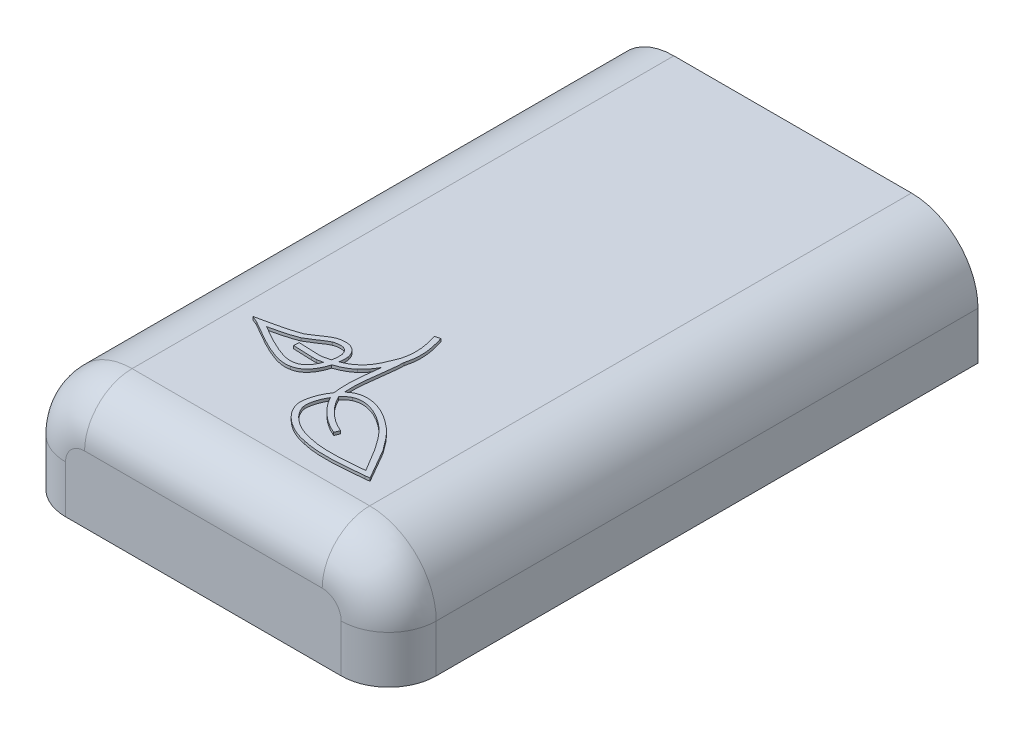
from build123d import *

# Parameters (mm, degrees)
BOSS_EXTRUDE1_DEPTH = 60
BOSS_EXTRUDE2_DEPTH = 2
BOSS_EXTRUDE3_START = 60
BOSS_EXTRUDE3_DEPTH = 2
FILLET1_R           = 5
BOSS_EXTRUDE4_DEPTH = 0.3


with BuildPart() as part:
    # Sketch1 → Boss-Extrude1 (new body)
    with BuildSketch(Plane.XY):
        with BuildLine():
            Line((-12.5, 0), (12.5, 0))
            ThreePointArc((12.5, 0), (16.035533906, -1.464466094), (17.5, -5))
            Line((17.5, -5), (17.5, -10))
            Line((17.5, -10), (19.5, -10))
            Line((19.5, -10), (19.5, -5))
            ThreePointArc((19.5, -5), (17.449747468, -0.050252532), (12.5, 2))
            Line((12.5, 2), (-12.5, 2))
            ThreePointArc((-12.5, 2), (-17.449747468, -0.050252532), (-19.5, -5))
            Line((-19.5, -5), (-19.5, -10))
            Line((-19.5, -10), (-17.5, -10))
            Line((-17.5, -10), (-17.5, -5))
            ThreePointArc((-17.5, -5), (-16.035533906, -1.464466094), (-12.5, 0))
        make_face()
    extrude(amount=BOSS_EXTRUDE1_DEPTH)

    # Sketch2 → Boss-Extrude2 (add)
    with BuildSketch(Plane.XY):
        with BuildLine():
            Line((19.5, -10), (19.5, -5))
            ThreePointArc((19.5, -5), (17.449747468, -0.050252532), (12.5, 2))
            Line((12.5, 2), (-12.5, 2))
            ThreePointArc((-12.5, 2), (-17.449747468, -0.050252532), (-19.5, -5))
            Line((-19.5, -5), (-19.5, -10))
            Line((-19.5, -10), (19.5, -10))
        make_face()
    extrude(amount=BOSS_EXTRUDE2_DEPTH)

    # Sketch2_2 → Boss-Extrude3 (add)
    with BuildSketch(Plane.XY.offset(BOSS_EXTRUDE3_START)):
        with BuildLine():
            Line((19.5, -10), (19.5, -5))
            ThreePointArc((19.5, -5), (17.449747468, -0.050252532), (12.5, 2))
            Line((12.5, 2), (-12.5, 2))
            ThreePointArc((-12.5, 2), (-17.449747468, -0.050252532), (-19.5, -5))
            Line((-19.5, -5), (-19.5, -10))
            Line((-19.5, -10), (19.5, -10))
        make_face()
    extrude(amount=BOSS_EXTRUDE3_DEPTH)

    # Fillet1
    fillet1_edges = [part.edges().sort_by_distance(p)[0] for p in [
        (-17.5, -7.5, 60),
        (-16.035533906, -1.464466094, 60),
        (0, 0, 60),
        (16.035533906, -1.464466094, 60),
        (-17.449747468, -0.050252532, 62),
        (17.449747468, -0.050252532, 62),
        (-19.5, -7.5, 62),
        (19.5, -7.5, 62),
        (0, 2, 62),
        (17.5, -7.5, 60),
    ]]
    fillet(fillet1_edges, radius=FILLET1_R)

    # Sketch4 → Boss-Extrude4 (add)
    with BuildSketch(Plane(origin=(0, 2, 0), x_dir=(1, 0, 0), z_dir=(0, 1, 0))):
        with BuildLine():
            Line((1.305736018, -38.316257091), (0.769961661, -38.466050797))
            add(Edge.make_bspline(
                [(0.967943194, -42.312720401), (1.020082146, -42.130005014), (1.110807126, -41.744125018), (1.200733766, -41.051660621), (1.183460904, -40.246056299), (1.017384191, -39.352294709), (0.852316866, -38.760614624), (0.769961661, -38.466050797)],
                knots=[0.002817102, 0.002817102, 0.002817102, 0.002817102, 0.125, 0.25, 0.5, 0.75, 1, 1, 1, 1], degree=3))
            add(Edge.make_bspline(
                [(-0.376582831, -44.774852536), (-0.226435782, -44.638475717), (0.02847593, -44.342224393), (0.377548216, -43.739641888), (0.680988093, -43.054163966), (0.873973024, -42.555843286), (0.967943194, -42.312720401)],
                knots=[0, 0, 0, 0, 0.251945629, 0.503891258, 0.755836887, 1.003516675, 1.003516675, 1.003516675, 1.003516675], degree=3))
            add(Edge.make_bspline(
                [(-1.932240131, -45.787781805), (-1.844054211, -45.755294083), (-1.496544164, -45.617487412), (-0.940875039, -45.321573069), (-0.548437196, -44.972120594), (-0.376582831, -44.774852536)],
                knots=[0.410600718, 0.410600718, 0.410600718, 0.410600718, 0.493105829, 0.742558143, 0.992010456, 0.992010456, 0.992010456, 0.992010456], degree=3))
            add(Edge.make_bspline(
                [(-1.932240131, -45.787781805), (-1.910487144, -45.642762357), (-1.876533024, -45.309761092), (-1.881885309, -45.018065715), (-1.901635199, -44.845397769)],
                knots=[0.782276391, 0.782276391, 0.782276391, 0.782276391, 0.875, 1, 1, 1, 1], degree=3))
            add(Edge.make_bspline(
                [(-1.901635199, -44.845397769), (-1.936880999, -44.700659604), (-2.041380386, -44.405271431), (-2.33902963, -43.970043621), (-2.870156527, -43.657028203), (-3.565289808, -43.619170476), (-4.007374858, -43.713856804), (-4.222868922, -43.779199908)],
                knots=[0, 0, 0, 0, 0.125, 0.25, 0.5, 0.75, 1, 1, 1, 1], degree=3))
            Line((-4.222868922, -43.779199908), (-4.252513102, -43.790227949))
            add(Edge.make_bspline(
                [(-4.252513102, -43.790227949), (-4.437245756, -43.872256827), (-4.794886171, -44.069542749), (-5.284985148, -44.406123293), (-5.773026094, -44.750841467), (-6.149527004, -44.98509211), (-6.333817629, -45.087591029)],
                knots=[0, 0, 0, 0, 0.25, 0.5, 0.75, 0.987399186, 0.987399186, 0.987399186, 0.987399186], degree=3))
            Line((-6.333817629, -45.087591029), (-6.456903008, -45.137791181))
            add(Edge.make_bspline(
                [(-6.456903008, -45.137791181), (-6.664324276, -45.216560327), (-7.118779261, -45.368290926), (-7.943840985, -45.594946681), (-8.868543406, -45.811548358), (-9.514173015, -45.951812739), (-9.833626772, -46.021161752)],
                knots=[0.041007081, 0.041007081, 0.041007081, 0.041007081, 0.25, 0.5, 0.75, 1, 1, 1, 1], degree=3))
            Line((-9.833626772, -46.021161752), (-10.61148624, -46.190001008))
            Line((-10.61148624, -46.190001008), (-9.909075714, -46.492663326))
            add(Edge.make_bspline(
                [(-9.909075714, -46.492663326), (-9.369524873, -46.809583815), (-8.268462012, -47.45652682), (-6.704621633, -48.272726864), (-5.522693637, -48.710729333), (-4.673469461, -48.830194372), (-4.289769667, -48.797262185), (-4.103573358, -48.749600749)],
                knots=[0, 0, 0, 0, 0.25, 0.5, 0.75, 0.875, 0.997000215, 0.997000215, 0.997000215, 0.997000215], degree=3))
            add(Edge.make_bspline(
                [(-4.103573358, -48.749600749), (-3.89873697, -48.717387756), (-3.488615582, -48.578908563), (-2.828201162, -48.086752347), (-2.33785236, -47.330783353), (-2.109681114, -46.6926985), (-2.043936433, -46.453754887)],
                knots=[0.002787495, 0.002787495, 0.002787495, 0.002787495, 0.125, 0.25, 0.5, 0.64892877, 0.64892877, 0.64892877, 0.64892877], degree=3))
            add(Edge.make_bspline(
                [(-2.043936433, -46.453754887), (-1.847859494, -46.388806949), (-1.362753984, -46.205194617), (-0.781706555, -45.890405926), (-0.417864369, -45.601797326), (-0.304238222, -45.499622903)],
                knots=[0.342175766, 0.342175766, 0.342175766, 0.342175766, 0.50564067, 0.756182367, 0.879437325, 0.879437325, 0.879437325, 0.879437325], degree=3))
            add(Edge.make_bspline(
                [(0.822015158, -44.061703082), (0.391710882, -44.885043117), (-0.304238222, -45.499622903)],
                knots=[0, 0, 0, 1, 1, 1], degree=2))
            add(Edge.make_bspline(
                [(0.61414643, -48.875814752), (0.536031707, -48.318804989), (0.489964594, -47.139288597), (0.635475737, -45.510588987), (0.769168684, -44.501846486), (0.822015158, -44.061703082)],
                knots=[0.017273768, 0.017273768, 0.017273768, 0.017273768, 0.25, 0.5, 0.710616893, 0.710616893, 0.710616893, 0.710616893], degree=3))
            add(Edge.make_bspline(
                [(-0.308490916, -51.720120687), (-0.328513028, -51.550714643), (-0.325403427, -51.217379272), (-0.194248107, -50.478609412), (0.080616649, -49.758267547), (0.412844612, -49.171828534), (0.554657805, -48.959246321), (0.61414643, -48.875814752)],
                knots=[0, 0, 0, 0, 0.125, 0.25, 0.5, 0.592221573, 0.654721573, 0.654721573, 0.654721573, 0.654721573], degree=3))
            add(Edge.make_bspline(
                [(3.415731617, -54.801857117), (3.170049909, -54.754654356), (2.673845998, -54.626002797), (1.779163927, -54.266829528), (0.822189087, -53.650641029), (0.011205277, -52.729829088), (-0.257723859, -52.073731551), (-0.308490916, -51.720120687)],
                knots=[0.001528741, 0.001528741, 0.001528741, 0.001528741, 0.125, 0.25, 0.5, 0.75, 1, 1, 1, 1], degree=3))
            add(Edge.make_bspline(
                [(9.827313858, -54.79974856), (9.251830693, -54.857015426), (8.086427952, -54.972810853), (6.419370386, -55.081315319), (4.830914811, -55.059379743), (3.887899334, -54.922339171), (3.415731617, -54.801857117)],
                knots=[0, 0, 0, 0, 0.25, 0.5, 0.75, 1, 1, 1, 1], degree=3))
            Line((9.827313858, -54.79974856), (10.291822093, -54.753524913))
            Line((10.291822093, -54.753524913), (10.056817126, -54.350192305))
            add(Edge.make_bspline(
                [(8.455934102, -51.566333768), (8.597305002, -51.817706755), (8.888618494, -52.331779401), (9.287944069, -53.027147746), (9.676739934, -53.697887797), (9.929506467, -54.131692497), (10.056817126, -54.350192305)],
                knots=[0, 0, 0, 0, 0.25, 0.5, 0.75, 1, 1, 1, 1], degree=3))
            Line((8.455934102, -51.566333768), (8.442087276, -51.544597531))
            add(Edge.make_bspline(
                [(5.989591152, -48.86138299), (6.26071159, -49.054674772), (6.786863503, -49.494691983), (7.422847793, -50.180940625), (7.975147695, -50.889311255), (8.282652867, -51.321953407), (8.442087276, -51.544597531)],
                knots=[0.001782641, 0.001782641, 0.001782641, 0.001782641, 0.25, 0.5, 0.75, 1, 1, 1, 1], degree=3))
            add(Edge.make_bspline(
                [(1.802005502, -47.806964304), (2.13630882, -47.659361353), (2.878611087, -47.52556079), (3.983325365, -47.726948381), (5.054880913, -48.200560925), (5.689103204, -48.625630033), (5.989591152, -48.86138299)],
                knots=[0, 0, 0, 0, 0.25, 0.5, 0.75, 1, 1, 1, 1], degree=3))
            add(Edge.make_bspline(
                [(1.108995098, -48.280717614), (1.317814196, -48.084300605), (1.545374893, -47.921916998), (1.802005502, -47.806964304)],
                knots=[0.814872426, 0.814872426, 0.814872426, 0.814872426, 1, 1, 1, 1], degree=3))
            add(Edge.make_bspline(
                [(1.108995098, -48.280717614), (1.082954836, -47.919220887), (1.071783476, -46.983567247), (1.215956247, -45.477701669), (1.411547768, -44.123637656), (1.521579499, -43.120153912), (1.548236432, -42.667596457), (1.55164109, -42.442424629)],
                knots=[0.091118743, 0.091118743, 0.091118743, 0.091118743, 0.25, 0.5, 0.75, 0.875, 0.993744196, 0.993744196, 0.993744196, 0.993744196], degree=3))
            add(Edge.make_bspline(
                [(1.55164109, -42.442424629), (1.604116282, -42.2485086), (1.696178393, -41.834980157), (1.78729639, -41.073843106), (1.75861373, -40.180754447), (1.56639307, -39.212342483), (1.393466701, -38.617924587), (1.305736018, -38.316257091)],
                knots=[0.007021086, 0.007021086, 0.007021086, 0.007021086, 0.125, 0.25, 0.5, 0.75, 1, 1, 1, 1], degree=3))
        make_face()
        with BuildLine():
            Line((-3.355048948, -46.218285797), (-3.87581467, -46.21712936))
            add(Edge.make_bspline(
                [(-5.771307686, -46.143246872), (-5.597845384, -46.154151602), (-5.243233327, -46.174917381), (-4.756566527, -46.197902428), (-4.293452235, -46.212926525), (-4.017797015, -46.216814068), (-3.87581467, -46.21712936)],
                knots=[0, 0, 0, 0, 0.25, 0.5, 0.75, 1, 1, 1, 1], degree=3))
            Line((-5.771307686, -46.143246872), (-5.806211931, -46.69847116))
            add(Edge.make_bspline(
                [(-5.806211931, -46.69847116), (-5.630937192, -46.709489829), (-5.273112454, -46.73044598), (-4.779143829, -46.753781852), (-4.307228159, -46.769112899), (-4.022986309, -46.773124252), (-3.877050053, -46.773448324)],
                knots=[0, 0, 0, 0, 0.25, 0.5, 0.75, 1, 1, 1, 1], degree=3))
            Line((-3.877050053, -46.773448324), (-3.323697798, -46.774677124))
            add(Edge.make_bspline(
                [(-3.323697798, -46.774677124), (-3.117360858, -46.740178309), (-2.910553514, -46.701855419), (-2.705929717, -46.657812275)],
                knots=[0.004557276, 0.004557276, 0.004557276, 0.004557276, 0.16739683, 0.16739683, 0.16739683, 0.16739683], degree=3))
            add(Edge.make_bspline(
                [(-4.232110243, -48.208205669), (-3.933138084, -48.166216838), (-3.386760245, -47.880362835), (-2.92717552, -47.195228102), (-2.742882488, -46.756221959), (-2.705929717, -46.657812275)],
                knots=[0, 0, 0, 0, 0.25, 0.5, 0.570755038, 0.570755038, 0.570755038, 0.570755038], degree=3))
            add(Edge.make_bspline(
                [(-8.96534307, -46.400676589), (-8.64539132, -46.586979521), (-7.784264847, -47.081929848), (-6.467366264, -47.768074107), (-5.364068931, -48.174044827), (-4.637222069, -48.269116585), (-4.371195862, -48.244996854), (-4.232110243, -48.208205669)],
                knots=[0.102247213, 0.102247213, 0.102247213, 0.102247213, 0.25, 0.5, 0.75, 0.875, 1, 1, 1, 1], degree=3))
            add(Edge.make_bspline(
                [(-6.128857021, -45.607222178), (-6.392097484, -45.711997078), (-6.912787368, -45.889106471), (-7.808500335, -46.134669277), (-8.504500956, -46.29769478), (-8.894488947, -46.384930755), (-8.96534307, -46.400676589)],
                knots=[0, 0, 0, 0, 0.25, 0.5, 0.75, 0.805348677, 0.805348677, 0.805348677, 0.805348677], degree=3))
            add(Edge.make_bspline(
                [(-4.072176069, -44.329978761), (-4.22795913, -44.399521312), (-4.527406441, -44.563740476), (-4.993169444, -44.879233211), (-5.49974806, -45.235036971), (-5.920894755, -45.494073126), (-6.128857021, -45.607222178)],
                knots=[0.008740908, 0.008740908, 0.008740908, 0.008740908, 0.25, 0.5, 0.75, 1, 1, 1, 1], degree=3))
            add(Edge.make_bspline(
                [(-2.44821326, -44.944418785), (-2.477262176, -44.840983034), (-2.564442243, -44.621089397), (-2.757082476, -44.370077112), (-3.050412019, -44.205350059), (-3.531363637, -44.182032635), (-3.902335462, -44.273061038), (-4.072176069, -44.329978761)],
                knots=[0, 0, 0, 0, 0.125, 0.25, 0.5, 0.75, 0.991649598, 0.991649598, 0.991649598, 0.991649598], degree=3))
            add(Edge.make_bspline(
                [(-2.511089701, -46.015664918), (-2.501590062, -45.968780292), (-2.46015582, -45.744911532), (-2.421164025, -45.354099954), (-2.429905161, -45.086365986), (-2.44821326, -44.944418785)],
                knots=[0.717012, 0.717012, 0.717012, 0.717012, 0.75, 0.875, 1, 1, 1, 1], degree=3))
            add(Edge.make_bspline(
                [(-3.355048948, -46.218285797), (-3.071746705, -46.160999242), (-2.784733589, -46.094072753), (-2.511089701, -46.015664918)],
                knots=[-0.005798798, -0.005798798, -0.005798798, -0.005798798, 0.231009853, 0.231009853, 0.231009853, 0.231009853], degree=3))
        make_face(mode=Mode.SUBTRACT)
        with BuildLine():
            Line((4.203372981, -52.497009964), (4.414717572, -51.982397703))
            add(Edge.make_bspline(
                [(4.414717572, -51.982397703), (4.064469171, -51.838553748), (3.397509515, -51.484405269), (2.475156925, -50.755592035), (1.735893574, -49.908855836), (1.36863171, -49.290128683), (1.226509439, -48.988876107)],
                knots=[0, 0, 0, 0, 0.25, 0.5, 0.75, 0.967074121, 0.967074121, 0.967074121, 0.967074121], degree=3))
            add(Edge.make_bspline(
                [(1.226509439, -48.988876107), (1.254550021, -48.955217584), (1.311371459, -48.889481554), (1.459814133, -48.730819266), (1.703590233, -48.510466649), (1.908263797, -48.381901934), (2.038191113, -48.323466634)],
                knots=[0.716089232, 0.716089232, 0.716089232, 0.716089232, 0.747339232, 0.778589232, 0.875, 1, 1, 1, 1], degree=3))
            add(Edge.make_bspline(
                [(2.038191113, -48.323466634), (2.300594285, -48.20584752), (2.867307046, -48.098275836), (3.821272498, -48.256333708), (4.794539257, -48.677896463), (5.385934596, -49.067851889), (5.664515101, -49.28334245)],
                knots=[0.000678589, 0.000678589, 0.000678589, 0.000678589, 0.25, 0.5, 0.75, 1, 1, 1, 1], degree=3))
            add(Edge.make_bspline(
                [(5.664515101, -49.28334245), (5.912495045, -49.468234951), (6.388304646, -49.884162078), (6.972649503, -50.542863315), (7.482188249, -51.226949301), (7.777422821, -51.662091489), (7.927011199, -51.881267817)],
                knots=[0, 0, 0, 0, 0.25, 0.5, 0.75, 0.995654256, 0.995654256, 0.995654256, 0.995654256], degree=3))
            add(Edge.make_bspline(
                [(7.927011199, -51.881267817), (8.071963444, -52.126705364), (8.372580707, -52.632039942), (8.785606575, -53.317437419), (9.118585735, -53.864982238), (9.312970458, -54.183440324), (9.375332283, -54.28554159)],
                knots=[0.004052914, 0.004052914, 0.004052914, 0.004052914, 0.25, 0.5, 0.75, 0.868383452, 0.868383452, 0.868383452, 0.868383452], degree=3))
            add(Edge.make_bspline(
                [(9.375332283, -54.28554159), (8.932698417, -54.329198587), (7.910664525, -54.426993604), (6.397645864, -54.52418546), (5.130267909, -54.508297417), (4.194392527, -54.402562296), (3.767958243, -54.317588106), (3.553279415, -54.262808956)],
                knots=[0.057619227, 0.057619227, 0.057619227, 0.057619227, 0.25, 0.5, 0.75, 0.875, 1, 1, 1, 1], degree=3))
            Line((3.553279415, -54.262808956), (3.537829364, -54.259370951))
            add(Edge.make_bspline(
                [(3.537829364, -54.259370951), (3.312388225, -54.216463734), (2.859054536, -54.099279311), (2.048377711, -53.774107075), (1.191185599, -53.218942467), (0.610247631, -52.560132513), (0.33721595, -52.021665337), (0.2695678, -51.774834788), (0.250731277, -51.643752329)],
                knots=[0, 0, 0, 0, 0.125, 0.25, 0.5, 0.75, 0.875, 1, 1, 1, 1], degree=3))
            add(Edge.make_bspline(
                [(0.250731277, -51.643752329), (0.235283844, -51.514113392), (0.237322276, -51.270968286), (0.346039625, -50.633606783), (0.565745703, -50.059003995), (0.790189932, -49.638958796), (0.842416955, -49.548285501), (0.866066309, -49.508561279)],
                knots=[0, 0, 0, 0, 0.125, 0.25, 0.5, 0.539298021, 0.570548021, 0.570548021, 0.570548021, 0.570548021], degree=3))
            add(Edge.make_bspline(
                [(4.203372981, -52.497009964), (3.820637568, -52.339827285), (3.089947188, -51.951866832), (2.089899267, -51.160850999), (1.355247417, -50.320851006), (0.990274612, -49.738785834), (0.866066309, -49.508561279)],
                knots=[0, 0, 0, 0, 0.25, 0.5, 0.75, 0.904572512, 0.904572512, 0.904572512, 0.904572512], degree=3))
        make_face(mode=Mode.SUBTRACT)
    extrude(amount=BOSS_EXTRUDE4_DEPTH)


solid = part.part
